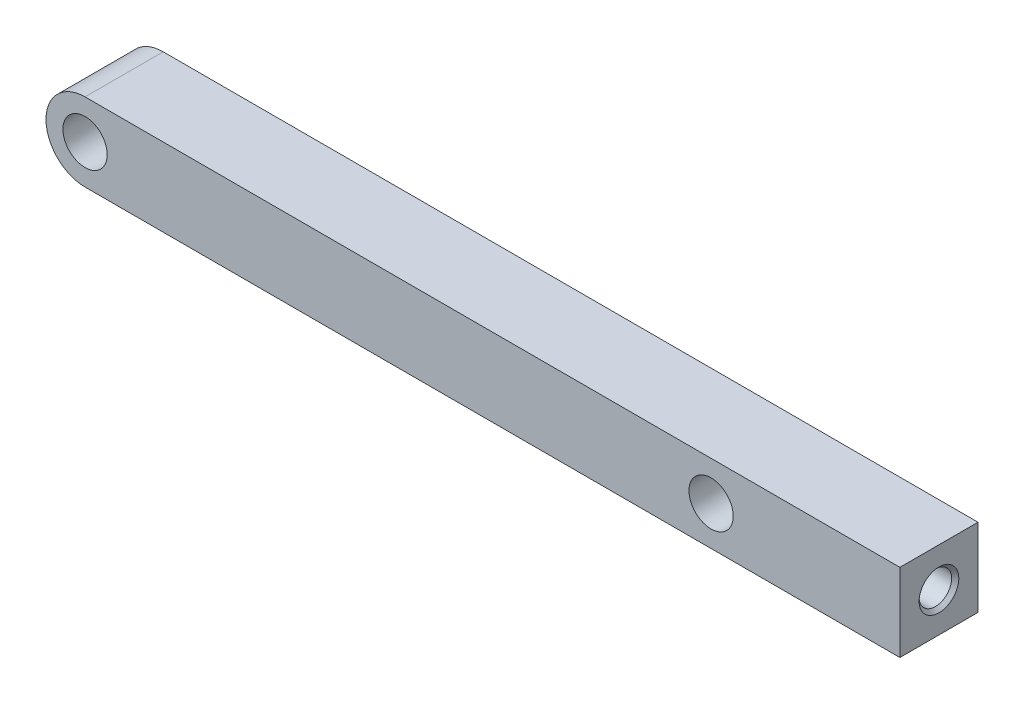
from build123d import *

# Parameters (mm, degrees)
SKETCH1_R                       = 1.7
BOSS_EXTRUDE1_DEPTH             = 3
M3X0_5_TAPPED_HOLE1_D           = 2.5
M3X0_5_TAPPED_HOLE1_DEPTH       = 6.748924226
M3X0_5_TAPPED_HOLE1_CSINK_D     = 3.05
M3X0_5_TAPPED_HOLE1_CSINK_ANGLE = 90
M3X0_5_TAPPED_HOLE1_TIP         = 0.751075774


with BuildPart() as part:
    # Sketch1 → Boss-Extrude1 (new body, symmetric)
    with BuildSketch(Plane.XY):
        with BuildLine():
            Line((38.54163056, 21.04163056), (38.54163056, 27.04163056))
            Line((38.54163056, 27.04163056), (24.04163056, 27.04163056))
            ThreePointArc((24.04163056, 27.04163056), (26.509317815, 25.747655066), (26.848253846, 22.981976969))
            ThreePointArc((26.848253846, 22.981976969), (26.592295747, 22.027653458), (26.528996798, 21.04163056))
            Line((26.528996798, 21.04163056), (38.54163056, 21.04163056))
        make_face()
        with BuildLine():
            ThreePointArc((26.848253846, 22.981976969), (26.509317815, 25.747655066), (24.04163056, 27.04163056))
            ThreePointArc((24.04163056, 27.04163056), (23.503053666, 26.992890449), (22.981976969, 26.848253846))
            ThreePointArc((22.981976969, 26.848253846), (20.97309248, 26.531857751), (19.004373338, 27.04163056))
            Line((19.004373338, 27.04163056), (-19.004373338, 27.04163056))
            ThreePointArc((-19.004373338, 27.04163056), (-20.97309248, 26.531857751), (-22.981976969, 26.848253846))
            ThreePointArc((-22.981976969, 26.848253846), (-23.503053666, 26.992890449), (-24.04163056, 27.04163056))
            ThreePointArc((-24.04163056, 27.04163056), (-26.509317815, 25.747655066), (-26.848253846, 22.981976969))
            ThreePointArc((-26.848253846, 22.981976969), (-25.747655066, 21.573943306), (-24.04163056, 21.04163056))
            Line((-24.04163056, 21.04163056), (26.528996798, 21.04163056))
            ThreePointArc((26.528996798, 21.04163056), (26.592295747, 22.027653458), (26.848253846, 22.981976969))
        make_face()
        with Locations((-24.04163056, 24.04163056)):
            Circle(SKETCH1_R, mode=Mode.SUBTRACT)
        with Locations((24.04163056, 24.04163056)):
            Circle(SKETCH1_R, mode=Mode.SUBTRACT)
        with BuildLine():
            ThreePointArc((22.981976969, 26.848253846), (23.503053666, 26.992890449), (24.04163056, 27.04163056))
            Line((24.04163056, 27.04163056), (19.004373338, 27.04163056))
            ThreePointArc((19.004373338, 27.04163056), (20.97309248, 26.531857751), (22.981976969, 26.848253846))
        make_face()
        with BuildLine():
            ThreePointArc((-22.981976969, 26.848253846), (-20.97309248, 26.531857751), (-19.004373338, 27.04163056))
            Line((-19.004373338, 27.04163056), (-24.04163056, 27.04163056))
            ThreePointArc((-24.04163056, 27.04163056), (-23.503053666, 26.992890449), (-22.981976969, 26.848253846))
        make_face()
    extrude(amount=BOSS_EXTRUDE1_DEPTH, both=True)

    # M3x0.5 Tapped Hole1
    with Locations(Plane(origin=(38.54163056, 24.04163056, 0), x_dir=(0, 0, 1), z_dir=(1, 0, 0))):
        with Locations((0, 0)):
            CounterSinkHole(M3X0_5_TAPPED_HOLE1_D / 2, M3X0_5_TAPPED_HOLE1_CSINK_D / 2, depth=M3X0_5_TAPPED_HOLE1_DEPTH, counter_sink_angle=M3X0_5_TAPPED_HOLE1_CSINK_ANGLE)
            with Locations((0, 0, -(M3X0_5_TAPPED_HOLE1_DEPTH + M3X0_5_TAPPED_HOLE1_TIP / 2))):  # 118° drill point
                Cone(0, M3X0_5_TAPPED_HOLE1_D / 2, M3X0_5_TAPPED_HOLE1_TIP, mode=Mode.SUBTRACT)


solid = part.part
